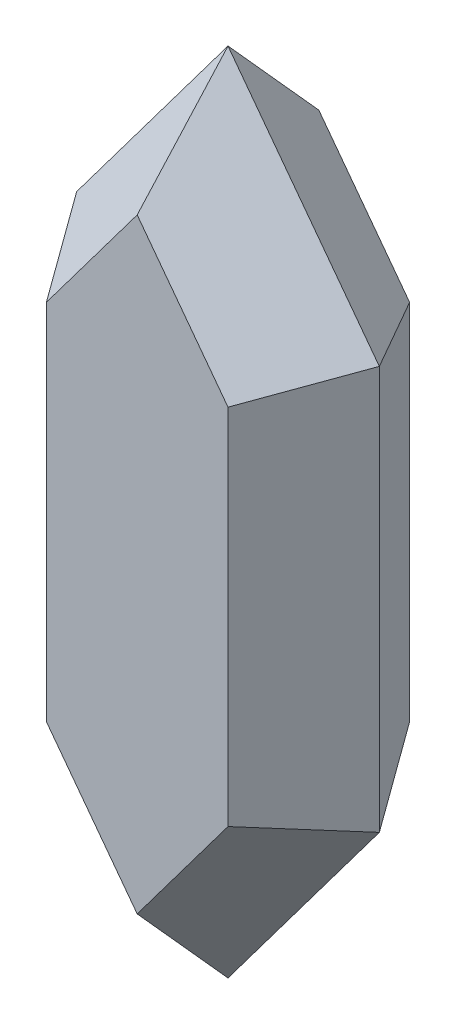
from build123d import *


with BuildPart() as part:
    # Base → Recubrir3 section 0
    with BuildSketch(Plane.XY):
        Polygon((27.5, 0), (27.5, 40), (12.5, 60), (-2.5, 40), (-2.5, 0), (12.5, -20), align=None)
    # Extrude 2 → Recubrir3 section 1
    with BuildSketch(Plane.XY.offset(9)):
        Polygon((3.5, 38), (3.5, 2), (12.5, -10), (21.5, 2), (21.5, 38), (12.5, 50), align=None)
    loft()

    # Base 2 → Recubrir4 section 0
    with BuildSketch(Plane.XY):
        Polygon((27.5, 0), (27.5, 40), (12.5, 60), (-2.5, 40), (-2.5, 0), (12.5, -20), align=None)
    # Croquis7 → Recubrir4 section 1
    with BuildSketch(Plane(origin=(0, 0, -9), x_dir=(-1, 0, 0), z_dir=(0, 0, -1))):
        Polygon((-21.5, 38), (-12.5, 50), (-3.5, 38), (-3.5, 2), (-12.5, -10), (-21.5, 2), align=None)
    loft()


solid = part.part
